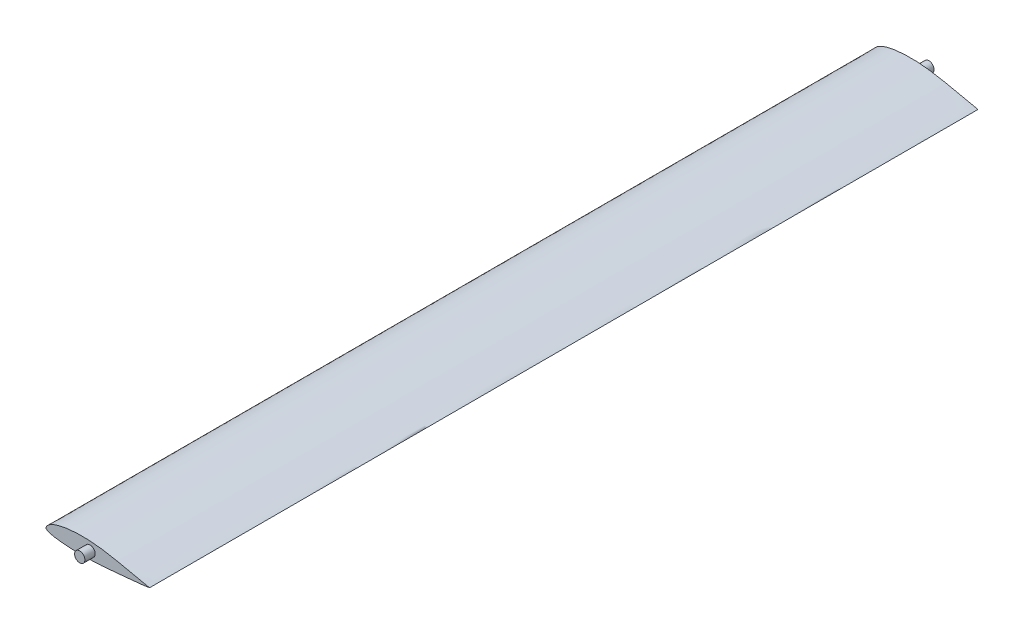
from build123d import *

# Parameters (mm, degrees)
BOSS_EXTRUDE1_DEPTH = 200
BOSS_EXTRUDE2_START = 200
SKETCH3_R           = 2.5
BOSS_EXTRUDE2_DEPTH = 5


with BuildPart() as part:
    # Sketch1 → Boss-Extrude1 (new body, symmetric)
    with BuildSketch(Plane.XY):
        with BuildLine():
            add(Edge.make_bspline(
                [(50, 0), (50.000196913, 0.005157273), (49.751775335, 0.035238085), (49.51840397, 0.115966697), (48.981133955, 0.254364808), (48.34748709, 0.424151123), (47.533184142, 0.603062226), (46.574084164, 0.801914942), (45.464712402, 1.028056924), (44.220368692, 1.28179457), (42.852888817, 1.562476509), (41.376886674, 1.867486388), (39.80666554, 2.194281913), (38.157275343, 2.538766368), (36.44393572, 2.895146676), (34.682080833, 3.257474963), (32.887552712, 3.617768349), (31.074173717, 3.967976856), (29.250255266, 4.289342581), (27.422632216, 4.571939457), (25.599124847, 4.819765733), (23.784554441, 5.021239171), (21.98649196, 5.172037783), (20.211784494, 5.277411667), (18.466617342, 5.329170385), (16.757686755, 5.332695736), (15.092148479, 5.289375046), (13.478692238, 5.19795185), (11.925055026, 5.064889132), (10.43938085, 4.889899141), (9.02998647, 4.67652427), (7.704281021, 4.426412781), (6.469272704, 4.140275149), (5.330501179, 3.82312045), (4.292933617, 3.476470194), (3.362477279, 3.100857208), (2.539037194, 2.707607882), (1.828502479, 2.294327463), (1.23279382, 1.870797743), (0.750625037, 1.443937102), (0.390002489, 1.013283416), (0.141997351, 0.593616134), (0.008161108, 0.210408045), (-0.01848952, -0.161269251), (0.213246282, -0.475119836), (0.595272522, -0.722527621), (1.120491831, -0.977510729), (1.79159049, -1.219379304), (2.604403753, -1.445142292), (3.554066687, -1.654798715), (4.63477553, -1.849454353), (5.840088335, -2.023530493), (7.161471022, -2.181337144), (8.590505023, -2.319332357), (10.116845798, -2.438159125), (11.730993628, -2.535294198), (13.422823762, -2.608090802), (15.182093644, -2.657123455), (16.998558319, -2.679873391), (18.862000314, -2.673603388), (20.762489064, -2.642843017), (22.690602559, -2.581024583), (24.635841968, -2.491605505), (26.589524656, -2.377116168), (28.543070331, -2.234327529), (30.488073636, -2.071391607), (32.413841104, -1.899693228), (34.30579497, -1.720529799), (36.15022361, -1.541253788), (37.932588041, -1.363935038), (39.638748905, -1.193693748), (41.254406466, -1.031710712), (42.765741269, -0.880312652), (44.159377805, -0.740822324), (45.422386039, -0.61457594), (46.543867462, -0.498488285), (47.510248048, -0.392410733), (48.329414637, -0.28862471), (48.968878442, -0.173192254), (49.511751252, -0.07860904), (49.749603368, -0.014270273), (49.999802857, -0.005163287), (50, 0)],
                knots=[0, 0, 0, 0, 0.001194464, 0.004539555, 0.009600523, 0.016135126, 0.024161431, 0.033727645, 0.044763238, 0.057156939, 0.070768722, 0.085470924, 0.101110136, 0.117540483, 0.134608347, 0.152143929, 0.169994788, 0.187984496, 0.206001687, 0.223999555, 0.24191162, 0.25966388, 0.277234721, 0.294525323, 0.311502719, 0.328142295, 0.344355241, 0.360082319, 0.375262469, 0.389821447, 0.403699304, 0.41682354, 0.429153753, 0.440657397, 0.45128421, 0.461037676, 0.469901239, 0.477873379, 0.484976797, 0.491187224, 0.496596218, 0.501303286, 0.505289755, 0.508453443, 0.511642851, 0.516040389, 0.521704123, 0.528624601, 0.536816542, 0.546288663, 0.556976167, 0.568832207, 0.581797357, 0.595780907, 0.61069645, 0.62644092, 0.642935375, 0.660077103, 0.677762785, 0.695908938, 0.714417309, 0.733190223, 0.752163165, 0.771202799, 0.79025942, 0.809282724, 0.828121153, 0.84664115, 0.864702525, 0.882161821, 0.898874989, 0.914704701, 0.929513625, 0.943169749, 0.95554687, 0.966535803, 0.976027756, 0.983961125, 0.990430109, 0.995460616, 0.998804142, 1, 1, 1, 1], degree=3))
        make_face()
    extrude(amount=BOSS_EXTRUDE1_DEPTH, both=True)

    # Sketch3 → Boss-Extrude2 (add)
    with BuildSketch(Plane.XY.offset(BOSS_EXTRUDE2_START)):
        with Locations((21.282586519, 1.043889944)):
            Circle(SKETCH3_R)
    boss_extrude2 = extrude(amount=BOSS_EXTRUDE2_DEPTH)

    # Mirror1: Boss-Extrude2 across plane
    add(boss_extrude2.mirror(Plane.XY))


solid = part.part
